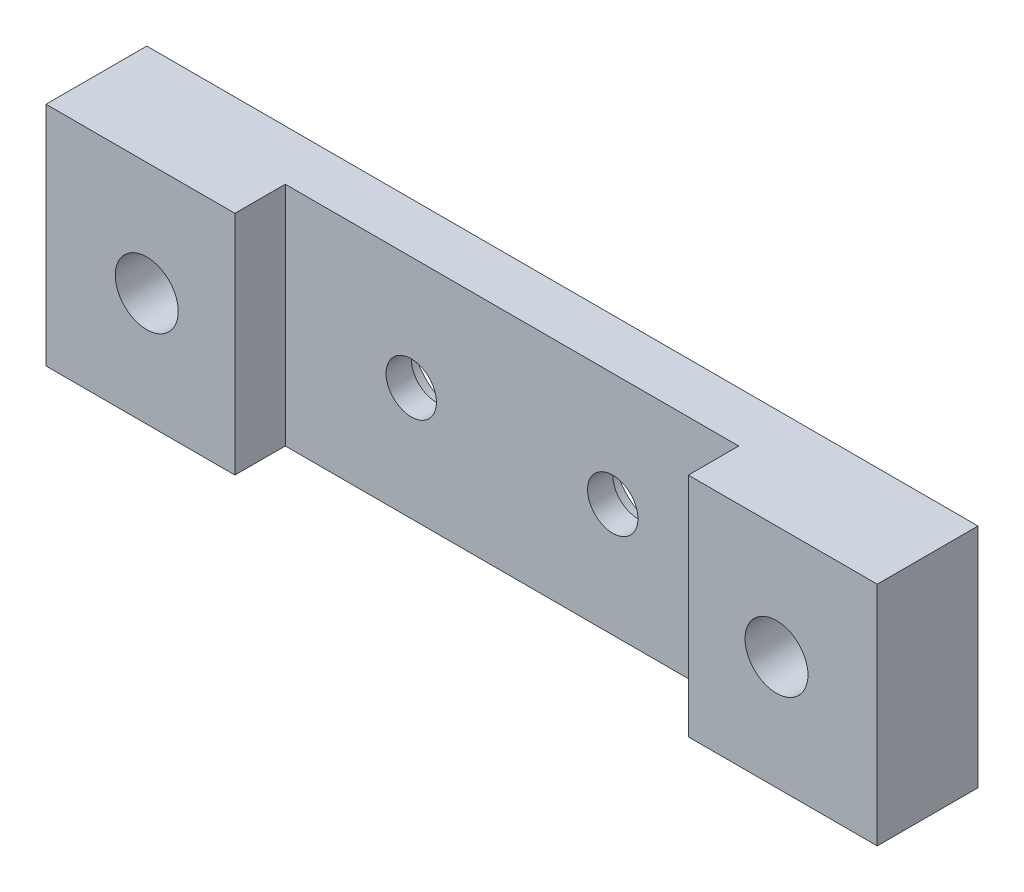
from build123d import *

# Parameters (mm, degrees)
BOSS_EXTRUDE1_DEPTH            = 28.575
HOLE1_D                        = 6.35
HOLE1_DEPTH                    = 12.7
HOLE1_CBORE_D                  = 12.7
HOLE1_CBORE_DEPTH              = 3.175
HOLE1_TIP                      = 1.907732465
F_5_16_0_3125_DIAMETER_HOLE1_D = 7.9375


with BuildPart() as part:
    # Sketch1 → Boss-Extrude1 (new body)
    with BuildSketch(Plane(origin=(0, 0, 0), x_dir=(1, 0, 0), z_dir=(0, 1, 0))):
        Polygon((-52.3875, 0), (52.3875, 0), (52.3875, -12.7), (28.575, -12.7), (28.575, -6.35), (-28.575, -6.35), (-28.575, -12.7), (-52.3875, -12.7), align=None)
    extrude(amount=BOSS_EXTRUDE1_DEPTH)

    # Hole1
    with Locations(Plane(origin=(0, 0, 0), x_dir=(-1, 0, 0), z_dir=(0, 0, -1))):
        with Locations((-12.7, 14.2875), (12.7, 14.2875)):
            CounterBoreHole(HOLE1_D / 2, HOLE1_CBORE_D / 2, HOLE1_CBORE_DEPTH, depth=HOLE1_DEPTH)
            with Locations((0, 0, -(HOLE1_DEPTH + HOLE1_TIP / 2))):  # 118° drill point
                Cone(0, HOLE1_D / 2, HOLE1_TIP, mode=Mode.SUBTRACT)

    # 5/16 (0.3125) Diameter Hole1 (through all)
    with Locations(Plane.XY.offset(12.7)):
        with Locations((-39.6875, 14.2875), (39.6875, 14.2875)):
            Hole(F_5_16_0_3125_DIAMETER_HOLE1_D / 2)


solid = part.part
